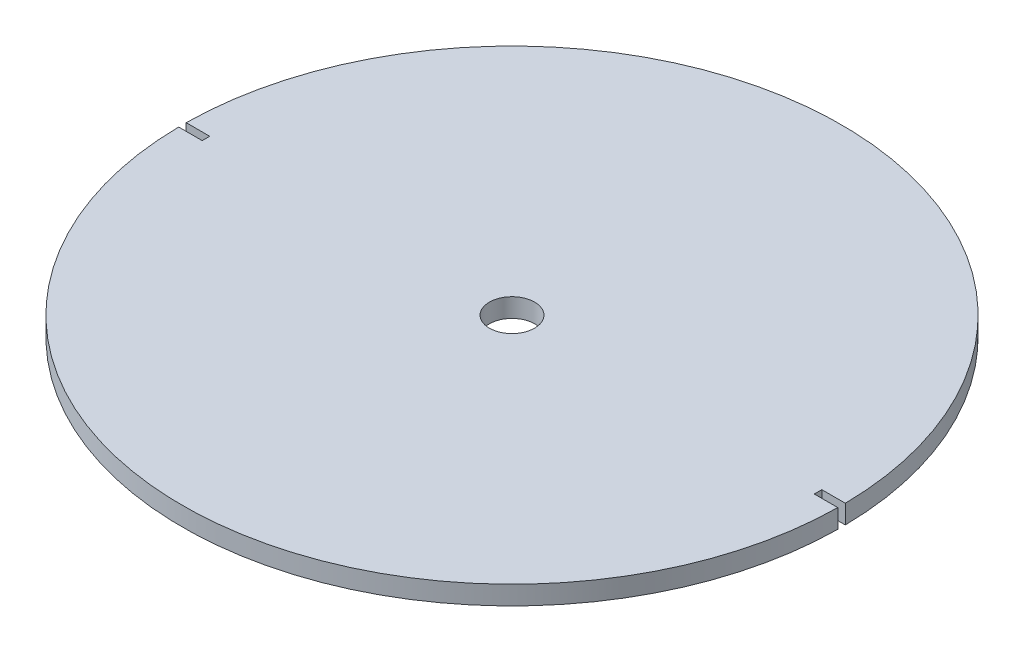
from build123d import *

# Parameters (mm, degrees)
SKETCH_3_R          = 35
EXTRUDE_1_DEPTH     = 2
SKETCH_4_W          = 5
SKETCH_4_H          = 0.8
CUT_EXTRUDE_6_DEPTH = 3
SKETCH_5_R          = 2.4
CUT_EXTRUDE_7_DEPTH = 3
CUT_EXTRUDE_8_DEPTH = 1


with BuildPart() as part:
    # 스케치3 → 보스-돌출1 (new body)
    with BuildSketch(Plane(origin=(0, 0, 0), x_dir=(1, 0, 0), z_dir=(0, 1, 0))):
        Circle(SKETCH_3_R)
    extrude(amount=EXTRUDE_1_DEPTH)

    # 스케치4 → 컷-돌출6 (cut, through all)
    with BuildSketch(Plane(origin=(0, 2, 0), x_dir=(1, 0, 0), z_dir=(0, 1, 0))):
        with Locations((-35, 0)):
            Rectangle(SKETCH_4_W, SKETCH_4_H)
        with Locations((35, 0)):
            Rectangle(SKETCH_4_W, SKETCH_4_H)
    extrude(amount=-CUT_EXTRUDE_6_DEPTH, mode=Mode.SUBTRACT)

    # 스케치5 → 컷-돌출7 (cut, through all)
    with BuildSketch(Plane(origin=(0, 2, 0), x_dir=(1, 0, 0), z_dir=(0, 1, 0))):
        Circle(SKETCH_5_R)
    extrude(amount=-CUT_EXTRUDE_7_DEPTH, mode=Mode.SUBTRACT)

    # 스케치6 → 컷-돌출8 (cut)
    with BuildSketch(Plane.XZ):
        Polygon((-22.083647797, 12.75), (-22.083647797, -12.75), (0, -25.5), (22.083647797, -12.75), (22.083647797, 12.75), (0, 25.5), align=None)
        Polygon((-20.883647797, 12.057179677), (-20.883647797, -12.057179677), (0, -24.114359354), (20.883647797, -12.057179677), (20.883647797, 12.057179677), (0, 24.114359354), align=None, mode=Mode.SUBTRACT)
    extrude(amount=-CUT_EXTRUDE_8_DEPTH, mode=Mode.SUBTRACT)


solid = part.part
